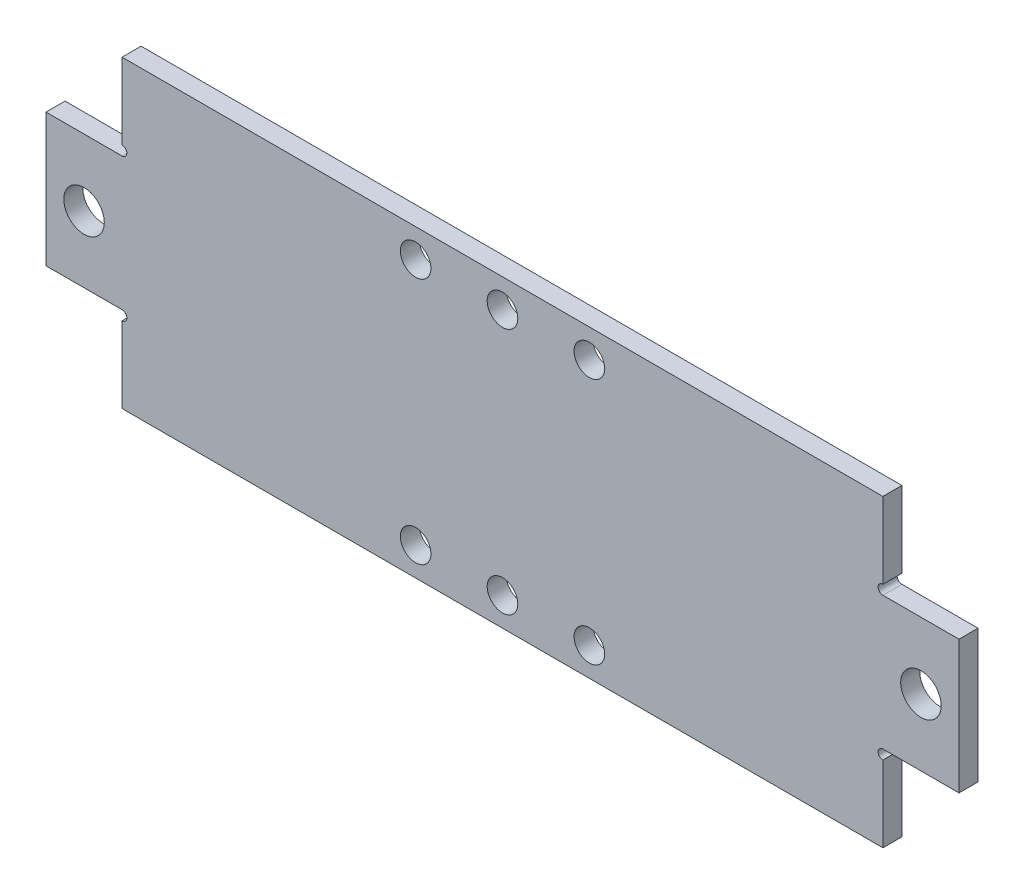
from build123d import *

# Parameters (mm, degrees)
SKETCH1_W               = 152.4
SKETCH1_H               = 50.8
BOSS_EXTRUDE1_DEPTH     = 3.175
SKETCH2_W               = 12.7
SKETCH2_H               = 14.2875
CUT_EXTRUDE1_DEPTH      = 4.175
SKETCH3_R               = 0.79375
CUT_EXTRUDE2_DEPTH      = 4.175
F_1_4_CLEARANCE_HOLE1_D = 6.7564
F_10_CLEARANCE_HOLE1_D  = 5.1054


with BuildPart() as part:
    # Sketch1 → Boss-Extrude1 (new body)
    with BuildSketch(Plane.XY):
        with Locations((76.2, 25.4)):
            Rectangle(SKETCH1_W, SKETCH1_H)
    extrude(amount=BOSS_EXTRUDE1_DEPTH)

    # Sketch2 → Cut-Extrude1 (cut, through all)
    with BuildSketch(Plane.XY.offset(3.175)):
        with Locations((6.35, 43.65625)):
            Rectangle(SKETCH2_W, SKETCH2_H)
        with Locations((6.35, 7.14375)):
            Rectangle(SKETCH2_W, SKETCH2_H)
        with Locations((146.05, 7.14375)):
            Rectangle(SKETCH2_W, SKETCH2_H)
        with Locations((146.05, 43.65625)):
            Rectangle(SKETCH2_W, SKETCH2_H)
    extrude(amount=-CUT_EXTRUDE1_DEPTH, mode=Mode.SUBTRACT)

    # Sketch3 → Cut-Extrude2 (cut, through all)
    with BuildSketch(Plane.XY.offset(3.175)):
        with Locations((12.7, 37.30625)):
            Circle(SKETCH3_R)
        with Locations((12.7, 13.49375)):
            Circle(SKETCH3_R)
        with Locations((139.7, 13.49375)):
            Circle(SKETCH3_R)
        with Locations((139.7, 37.30625)):
            Circle(SKETCH3_R)
    extrude(amount=-CUT_EXTRUDE2_DEPTH, mode=Mode.SUBTRACT)

    # 1/4 Clearance Hole1 (through all)
    with Locations(Plane.XY.offset(3.175)):
        with Locations((6.35, 25.4), (146.05, 25.4)):
            Hole(F_1_4_CLEARANCE_HOLE1_D / 2)

    # #10 Clearance Hole1 (through all)
    with Locations(Plane.XY.offset(3.175)):
        with Locations((76.2, 4.7625), (90.7, 4.7625), (61.7, 4.7625), (61.7, 46.0375), (76.2, 46.0375), (90.7, 46.0375)):
            Hole(F_10_CLEARANCE_HOLE1_D / 2)


solid = part.part
